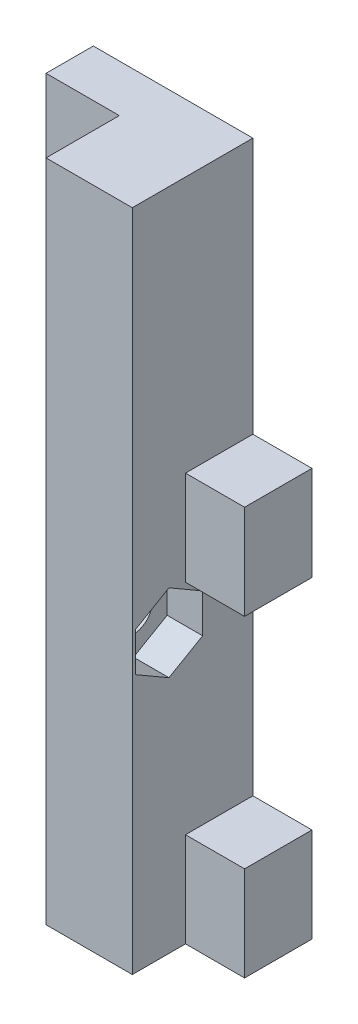
from build123d import *

# Parameters (mm, degrees)
SALIENTE_EXTRUIR3_DEPTH = 4
SALIENTE_EXTRUIR4_DEPTH = 1.7
CROQUIS7_W              = 7.3
CROQUIS7_H              = 34.5
SALIENTE_EXTRUIR5_DEPTH = 4.5
CORTAR_EXTRUIR3_REACH   = 15.5
CROQUIS8_R              = 1.6
CORTAR_EXTRUIR4_DEPTH   = 3
SALIENTE_EXTRUIR6_DEPTH = 21.7


with BuildPart() as part:
    # Croquis5 → Saliente-Extruir3 (new body)
    with BuildSketch(Plane.XY):
        Polygon((18.5, 26.5), (18.5, 34.5), (0, 34.5), (0, 0), (18.5, 0), (18.5, 8), (13.5, 8), (13.5, 26.5), align=None)
    extrude(amount=SALIENTE_EXTRUIR3_DEPTH)

    # Croquis6 → Saliente-Extruir4 (add)
    with BuildSketch(Plane.XY.offset(4)):
        Polygon((6.2, 34.5), (6.2, 0), (18.5, 0), (18.5, 8), (13.5, 8), (13.5, 26.5), (18.5, 26.5), (18.5, 34.5), align=None)
    extrude(amount=SALIENTE_EXTRUIR4_DEPTH)

    # Croquis7 → Saliente-Extruir5 (add)
    with BuildSketch(Plane.XY.offset(5.7)):
        with Locations((9.85, 17.25)):
            Rectangle(CROQUIS7_W, CROQUIS7_H)
    extrude(amount=SALIENTE_EXTRUIR5_DEPTH)

    # Croquis8 → Cortar-Extruir3 (cut, up to next)
    with BuildSketch(Plane(origin=(13.5, 0, 0), x_dir=(0, 0, -1), z_dir=(1, 0, 0)), mode=Mode.PRIVATE) as cortar_extruir3_sk1:
        with Locations((-7.1, 23.5)):
            Circle(CROQUIS8_R)
    cortar_extruir3_tool1 = extrude(cortar_extruir3_sk1.sketch, amount=-CORTAR_EXTRUIR3_REACH, mode=Mode.PRIVATE) & part.part
    add(cortar_extruir3_tool1.solids().sort_by_distance((13.5, 23.5, 7.1))[0], mode=Mode.SUBTRACT)

    # Croquis9 → Cortar-Extruir4 (cut)
    with BuildSketch(Plane(origin=(13.5, 0, 0), x_dir=(0, 0, -1), z_dir=(1, 0, 0))):
        Polygon((-7.1, 26.790896534), (-9.95, 25.145448267), (-9.95, 21.854551733), (-7.1, 20.209103466), (-4.25, 21.854551733), (-4.25, 25.145448267), align=None)
    extrude(amount=-CORTAR_EXTRUIR4_DEPTH, mode=Mode.SUBTRACT)

    # Croquis10 → Saliente-Extruir6 (add)
    with BuildSketch(Plane(origin=(0, 34.5, 0), x_dir=(1, 0, 0), z_dir=(0, 1, 0))):
        Polygon((13.5, -5.7), (13.5, 0), (0, 0), (0, -4), (6.2, -4), (6.2, -10.2), (13.5, -10.2), align=None)
    extrude(amount=SALIENTE_EXTRUIR6_DEPTH)


solid = part.part
